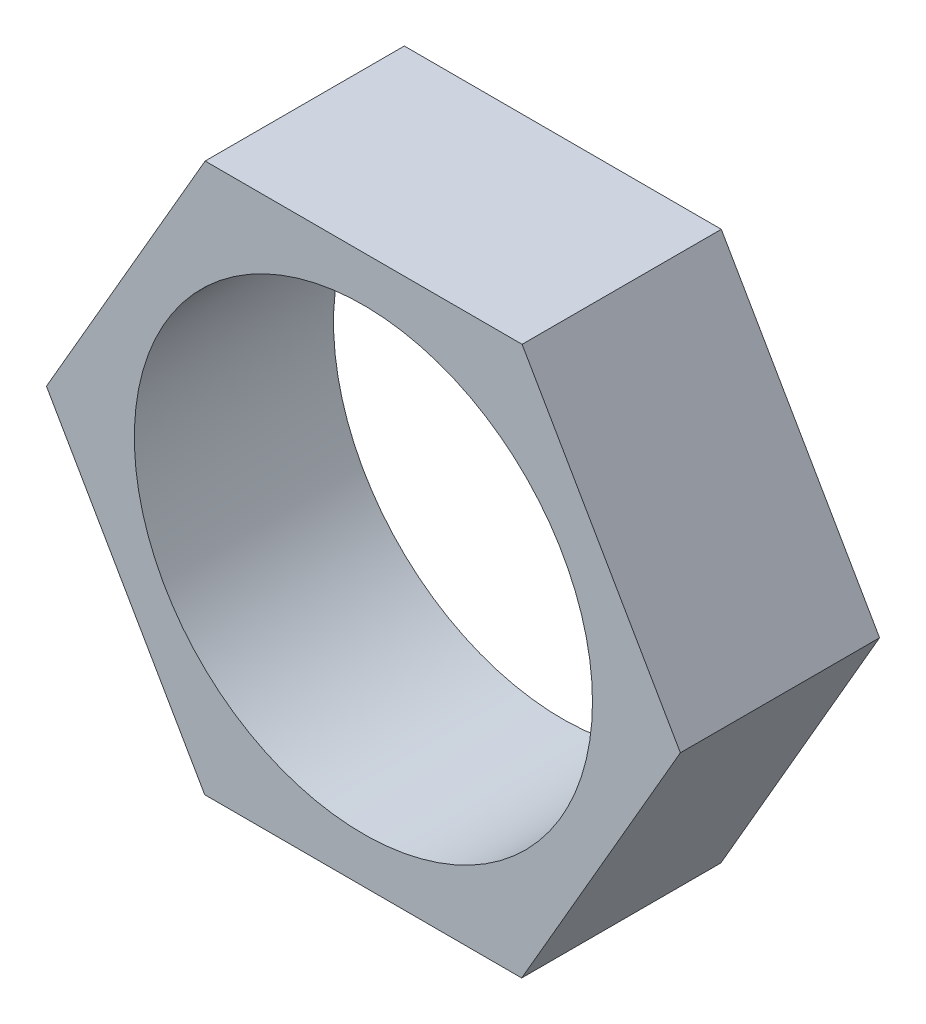
from build123d import *

# Parameters (mm, degrees)
CROQUIS1_R              = 11.5
SALIENTE_EXTRUIR1_DEPTH = 10


with BuildPart() as part:
    # Croquis1 → Saliente-Extruir1 (new body)
    with BuildSketch(Plane.XY):
        Polygon((7.966989997, 13.774204899), (-7.94531636, 13.786718179), (-15.912306358, 0.01251328), (-7.966989997, -13.774204899), (7.94531636, -13.786718179), (15.912306358, -0.01251328), align=None)
        Circle(CROQUIS1_R, mode=Mode.SUBTRACT)
    extrude(amount=SALIENTE_EXTRUIR1_DEPTH)


solid = part.part
